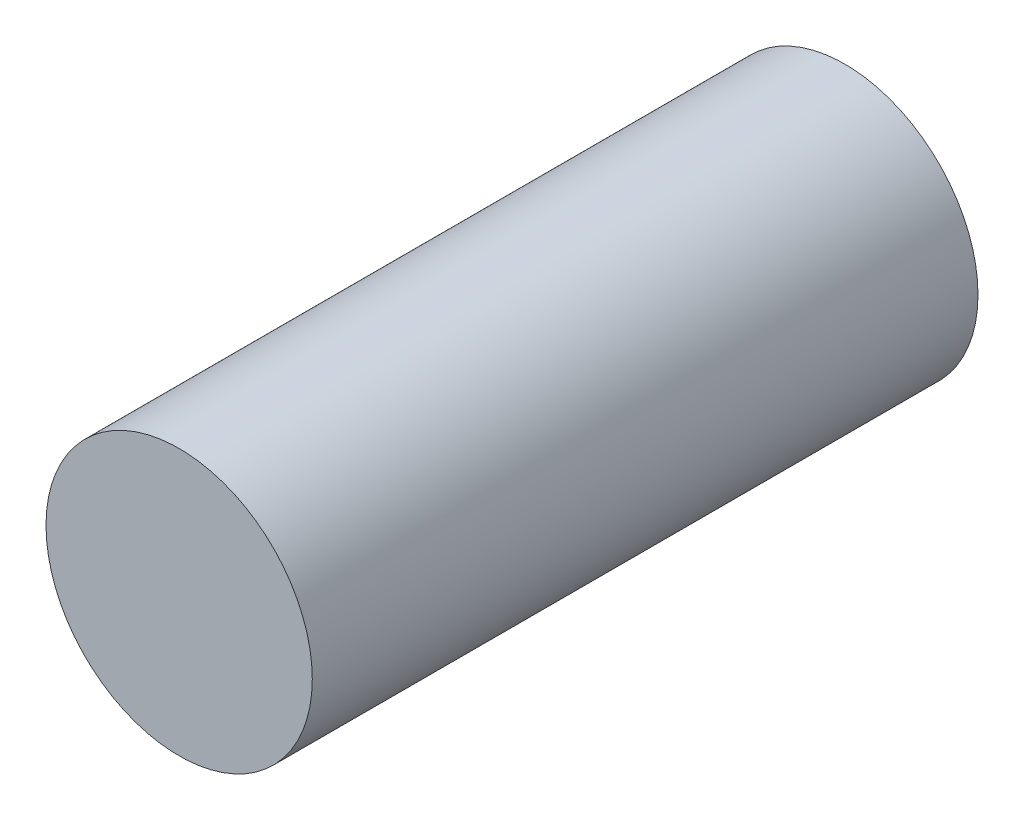
from build123d import *

# Parameters (mm, degrees)
SKETCH1_R           = 20
BOSS_EXTRUDE1_DEPTH = 100


with BuildPart() as part:
    # Sketch1 → Boss-Extrude1 (new body)
    with BuildSketch(Plane.XY):
        with Locations((-39.7871289, 20.348274495)):
            Circle(SKETCH1_R)
    extrude(amount=BOSS_EXTRUDE1_DEPTH)


solid = part.part
